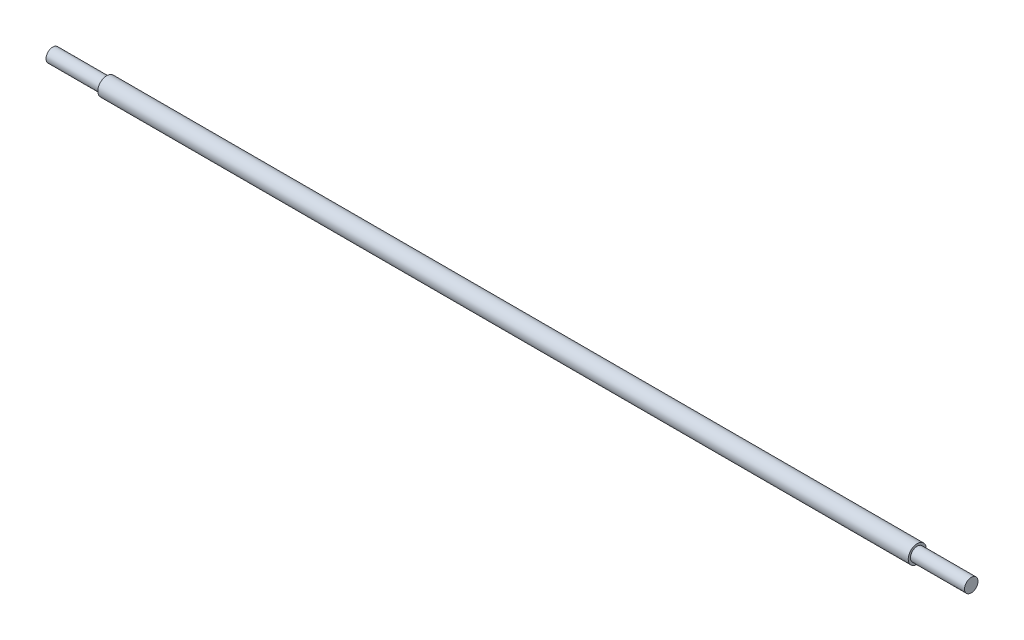
from build123d import *


with BuildPart() as part:
    # Sketch2 → Revolve1 (revolve)
    with BuildSketch(Plane(origin=(0, 0, 0), x_dir=(1, 0, 0), z_dir=(0, 1, 0))):
        Polygon((-647.7, 0), (647.7, 0), (647.7, 9.525), (571.5, 9.525), (571.5, 12.7), (-571.5, 12.7), (-571.5, 9.525), (-647.7, 9.525), align=None)
    revolve(axis=Axis((-647.7, 0, 0), (1, 0, 0)))


solid = part.part
